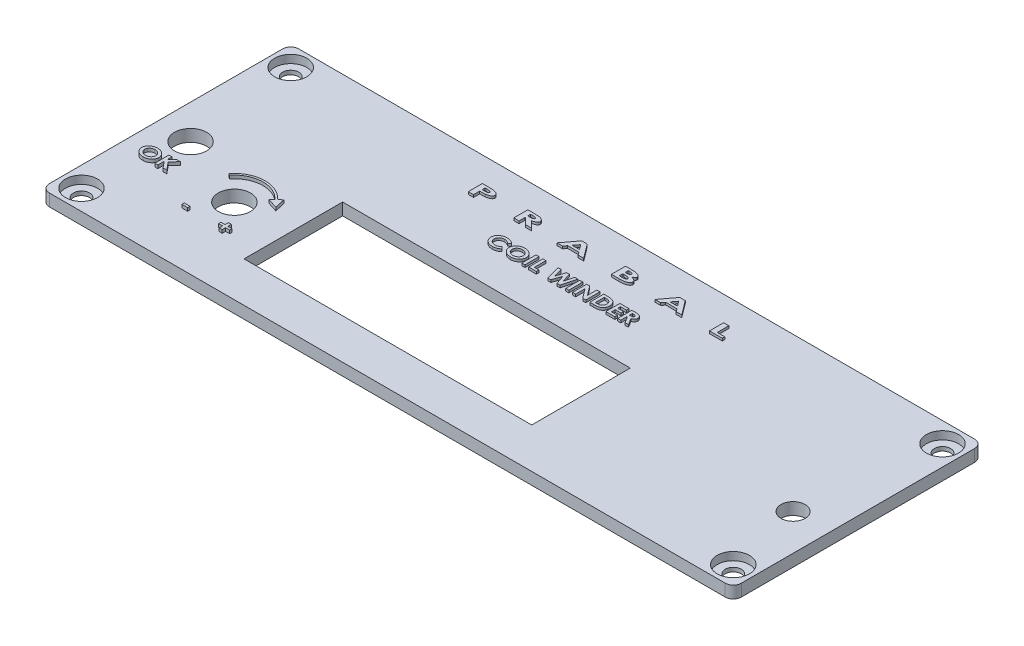
from build123d import *

# Parameters (mm, degrees)
SKETCH1_R           = 2
BOSS_EXTRUDE1_DEPTH = 3
SKETCH2_R           = 4
CUT_EXTRUDE1_DEPTH  = 2
SKETCH3_R           = 4
SKETCH3_R_2         = 3
SKETCH3_W           = 71.5
SKETCH3_H           = 24.5
CUT_EXTRUDE2_DEPTH  = 12
SKETCH4_W           = 1.435897436
SKETCH4_H           = 0.583333333
BOSS_EXTRUDE2_DEPTH = 0.8
SKETCH6_W           = 0.762820513
SKETCH6_H           = 3.5
BOSS_EXTRUDE3_DEPTH = 0.6


with BuildPart() as part:
    # Sketch1 → Boss-Extrude1 (new body)
    with BuildSketch(Plane(origin=(0, 0, 0), x_dir=(1, 0, 0), z_dir=(0, 1, 0))):
        with BuildLine():
            Line((86, -29), (86, 29))
            ThreePointArc((86, 29), (85.414213562, 30.414213562), (84, 31))
            Line((84, 31), (-84, 31))
            ThreePointArc((-84, 31), (-85.414213562, 30.414213562), (-86, 29))
            Line((-86, 29), (-86, -29))
            ThreePointArc((-86, -29), (-85.414213562, -30.414213562), (-84, -31))
            Line((-84, -31), (84, -31))
            ThreePointArc((84, -31), (85.414213562, -30.414213562), (86, -29))
        make_face()
        with Locations(Location((81, 26, 0), (0, 0, 270))):  # turned: the seam where the file's is
            Circle(SKETCH1_R, mode=Mode.SUBTRACT)
        with Locations(Location((81, -26, 0), (0, 0, 270))):  # turned: the seam where the file's is
            Circle(SKETCH1_R, mode=Mode.SUBTRACT)
        with Locations(Location((-81, -26, 0), (0, 0, 270))):  # turned: the seam where the file's is
            Circle(SKETCH1_R, mode=Mode.SUBTRACT)
        with Locations(Location((-81, 26, 0), (0, 0, 270))):  # turned: the seam where the file's is
            Circle(SKETCH1_R, mode=Mode.SUBTRACT)
    extrude(amount=BOSS_EXTRUDE1_DEPTH)

    # Sketch2 → Cut-Extrude1 (cut)
    with BuildSketch(Plane(origin=(0, 3, 0), x_dir=(1, 0, 0), z_dir=(0, 1, 0))):
        with Locations(Location((-81, 26, 0), (0, 0, 270))):  # turned: the seam where the file's is
            Circle(SKETCH2_R)
        with Locations(Location((81, 26, 0), (0, 0, 270))):  # turned: the seam where the file's is
            Circle(SKETCH2_R)
        with Locations(Location((-81, -26, 0), (0, 0, 270))):  # turned: the seam where the file's is
            Circle(SKETCH2_R)
        with Locations(Location((81, -26, 0), (0, 0, 270))):  # turned: the seam where the file's is
            Circle(SKETCH2_R)
    extrude(amount=-CUT_EXTRUDE1_DEPTH, mode=Mode.SUBTRACT)

    # Sketch3 → Cut-Extrude2 (cut)
    with BuildSketch(Plane(origin=(0, 3, 0), x_dir=(1, 0, 0), z_dir=(0, 1, 0))):
        with Locations(Location((-77.5, -2.4, 0), (0, 0, 270))):  # turned: the seam where the file's is
            Circle(SKETCH3_R)
        with Locations(Location((-59, -10, 0), (0, 0, 270))):  # turned: the seam where the file's is
            Circle(SKETCH3_R)
        with Locations(Location((76.991675758, -7.128858866, 0), (0, 0, 270))):  # turned: the seam where the file's is
            Circle(SKETCH3_R_2)
        with Locations((-9.85, -8.75)):
            Rectangle(SKETCH3_W, SKETCH3_H)
    extrude(amount=-CUT_EXTRUDE2_DEPTH, mode=Mode.SUBTRACT)

    # Sketch4 → Boss-Extrude2 (add)
    with BuildSketch(Plane(origin=(0, 3, 0), x_dir=(1, 0, 0), z_dir=(0, 1, 0))):
        with BuildLine():
            Line((-51.988382375, -6.724877483), (-52.556552367, -4.128219119))
            Line((-52.556552367, -4.128219119), (-53.359319029, -4.859763814))
            ThreePointArc((-53.359319029, -4.859763814), (-59.291497182, -2.374100757), (-65.016615493, -5.305359665))
            Line((-65.016615493, -5.305359665), (-64.622417733, -5.612944005))
            ThreePointArc((-64.622417733, -5.612944005), (-59.272398814, -2.873735877), (-53.728886239, -5.196542788))
            Line((-53.728886239, -5.196542788), (-54.52123948, -5.918597948))
            Line((-54.52123948, -5.918597948), (-51.988382375, -6.724877483))
        make_face()
        with BuildLine():
            add(Edge.make_bspline(
                [(-79.353333582, -8.706413119), (-79.281274588, -8.707971377), (-79.139274606, -8.711042093), (-78.930061876, -8.737121757), (-78.728448964, -8.778747518), (-78.534599499, -8.837959657), (-78.348694874, -8.913942148), (-78.170569568, -9.006930794), (-78.000279378, -9.116866731), (-77.866189353, -9.221479716), (-77.764512107, -9.311988503), (-77.69248916, -9.381731382), (-77.625225914, -9.453535126), (-77.564168185, -9.527840465), (-77.506507602, -9.603064925), (-77.455006675, -9.680874795), (-77.407917672, -9.76016674), (-77.365359297, -9.841197599), (-77.328721035, -9.92432177), (-77.295847214, -10.009080225), (-77.268903659, -10.095838462), (-77.245957229, -10.184407073), (-77.229783297, -10.274976568), (-77.21654424, -10.367040711), (-77.209887655, -10.461223578), (-77.208567499, -10.524647692), (-77.20790089, -10.556673535)],
                knots=[0, 0, 0, 0, 1.648128368, 3.247813819, 4.815582138, 6.353077473, 7.87824102, 9.404088637, 10.943618834, 12.509489415, 13.289676537, 14.057284384, 14.80259305, 15.539239416, 16.256815247, 16.970135158, 17.672570217, 18.366137315, 19.062686628, 19.74985535, 20.444904871, 21.140016092, 21.841616263, 22.548655906, 23.267147546, 24, 24, 24, 24], degree=3))
            add(Edge.make_bspline(
                [(-77.20790089, -10.556673535), (-77.208166311, -10.588244217), (-77.208694049, -10.65101636), (-77.217170278, -10.744084598), (-77.228461875, -10.835742881), (-77.246473725, -10.92523373), (-77.267957099, -11.013111077), (-77.294609907, -11.09915263), (-77.327134701, -11.182926582), (-77.363400414, -11.265297967), (-77.405133477, -11.345441036), (-77.451241969, -11.423995946), (-77.502789182, -11.500577492), (-77.558756844, -11.575613207), (-77.619876061, -11.648619407), (-77.686136016, -11.71949082), (-77.756813208, -11.788967798), (-77.857358382, -11.878037202), (-77.990149062, -11.981441584), (-78.159389854, -12.089620643), (-78.337132613, -12.181221073), (-78.522891316, -12.256628153), (-78.717282644, -12.314919962), (-78.920025577, -12.356080533), (-79.131151553, -12.381083869), (-79.274739141, -12.384277154), (-79.347724608, -12.385900298)],
                knots=[0, 0, 0, 0, 0.725776301, 1.443064634, 2.147736794, 2.848709645, 3.540911308, 4.227708172, 4.918447597, 5.606610135, 6.29653354, 6.995256734, 7.700359215, 8.418432472, 9.147207738, 9.888792953, 10.648941586, 11.425594641, 12.976974662, 14.514175085, 16.038230067, 17.569291758, 19.118361041, 20.698449866, 22.321824455, 24, 24, 24, 24], degree=3))
            add(Edge.make_bspline(
                [(-79.347724608, -12.385900298), (-79.424000764, -12.384459059), (-79.573507006, -12.381634137), (-79.792599759, -12.354284369), (-80.002323966, -12.313617749), (-80.20158508, -12.252105916), (-80.391859271, -12.176392393), (-80.571519819, -12.081307765), (-80.741815747, -11.970536391), (-80.899855422, -11.843418403), (-81.04317275, -11.704928133), (-81.169984337, -11.558924691), (-81.276039391, -11.405284469), (-81.364345894, -11.245994389), (-81.431592095, -11.079592941), (-81.480542091, -10.907171034), (-81.509909045, -10.728051412), (-81.513683776, -10.606327614), (-81.515593198, -10.544754465)],
                knots=[0, 0, 0, 0, 1.157019011, 2.26783273, 3.345970481, 4.39501922, 5.427728631, 6.449416413, 7.47446608, 8.506395619, 9.522255368, 10.495542035, 11.436096042, 12.350383781, 13.254015284, 14.153355931, 15.06588776, 16, 16, 16, 16], degree=3))
            add(Edge.make_bspline(
                [(-81.515593198, -10.544754465), (-81.51492466, -10.503342903), (-81.513594967, -10.420977152), (-81.498628609, -10.298965283), (-81.47670678, -10.17930472), (-81.444524469, -10.062563164), (-81.405080017, -9.947772806), (-81.354458216, -9.836241685), (-81.296562181, -9.726467816), (-81.228877161, -9.620292431), (-81.154589064, -9.51742531), (-81.071839241, -9.420372195), (-80.98284536, -9.328579918), (-80.887260078, -9.241881457), (-80.784408607, -9.161528847), (-80.675889814, -9.085249176), (-80.559463856, -9.016046404), (-80.437490612, -8.952036214), (-80.31121725, -8.893553349), (-80.181098328, -8.844354951), (-80.04921584, -8.800758528), (-79.914497363, -8.767234742), (-79.777827625, -8.738904541), (-79.638350639, -8.720914659), (-79.496605826, -8.707987117), (-79.401273886, -8.706939794), (-79.353333582, -8.706413119)],
                knots=[0, 0, 0, 0, 0.945898682, 1.881350319, 2.80526485, 3.723868994, 4.646145679, 5.576184113, 6.51996939, 7.480160434, 8.451252179, 9.417558632, 10.392051965, 11.371436227, 12.36407087, 13.373066218, 14.400787555, 15.456751901, 16.52026678, 17.578619197, 18.63425932, 19.69259826, 20.749480695, 21.822076479, 22.904770899, 24, 24, 24, 24], degree=3))
        make_face()
        with BuildLine():
            add(Edge.make_bspline(
                [(-79.364551531, -9.334618247), (-79.41250994, -9.335701272), (-79.506832958, -9.33783133), (-79.645391477, -9.354469021), (-79.778334015, -9.380580006), (-79.905189159, -9.418840851), (-80.026270674, -9.467364637), (-80.141875935, -9.526177891), (-80.250872301, -9.597018114), (-80.353410472, -9.676995872), (-80.446849189, -9.765308633), (-80.529062982, -9.86039568), (-80.597929953, -9.961728889), (-80.654582707, -10.068691282), (-80.699420437, -10.181364609), (-80.72947208, -10.300469451), (-80.749436738, -10.424893419), (-80.751646187, -10.509851612), (-80.752772685, -10.553167926)],
                knots=[0, 0, 0, 0, 1.115572756, 2.194071725, 3.242359846, 4.264238554, 5.271971266, 6.273921791, 7.276948881, 8.291830226, 9.295741301, 10.263602405, 11.21075812, 12.139965089, 13.075008802, 14.024611973, 14.992839609, 16, 16, 16, 16], degree=3))
            add(Edge.make_bspline(
                [(-80.752772685, -10.553167926), (-80.7514151, -10.601184814), (-80.748748553, -10.69549878), (-80.724110747, -10.8327498), (-80.685094049, -10.962574198), (-80.628772796, -11.084143892), (-80.557798422, -11.198455529), (-80.470306051, -11.304401317), (-80.367397012, -11.402899623), (-80.288902041, -11.459467921), (-80.248666115, -11.488464401)],
                knots=[0, 0, 0, 0, 1.037914569, 2.038654397, 3.006201782, 3.963123752, 4.928290618, 5.909010015, 6.928174417, 8, 8, 8, 8], degree=3))
            add(Edge.make_bspline(
                [(-80.248666115, -11.488464401), (-80.215807341, -11.510038688), (-80.1504234, -11.552968226), (-80.046641333, -11.607660127), (-79.939426142, -11.653819122), (-79.828638803, -11.692064897), (-79.714188007, -11.721417336), (-79.596070329, -11.742348932), (-79.474451988, -11.755349209), (-79.39216143, -11.756907036), (-79.350529095, -11.75769517)],
                knots=[0, 0, 0, 0, 0.990243603, 1.970433532, 2.951896849, 3.929818883, 4.921270474, 5.926466457, 6.950960545, 8, 8, 8, 8], degree=3))
            add(Edge.make_bspline(
                [(-79.350529095, -11.75769517), (-79.303509904, -11.756587552), (-79.211059443, -11.754409723), (-79.075171223, -11.738127785), (-78.944814148, -11.710594147), (-78.819383876, -11.672775522), (-78.699219421, -11.623842083), (-78.585022639, -11.562801385), (-78.475972895, -11.491674671), (-78.372891864, -11.411099854), (-78.278717308, -11.322122528), (-78.196419718, -11.226764745), (-78.126868742, -11.126134173), (-78.069772169, -11.020658765), (-78.025115492, -10.909667394), (-77.993861248, -10.793625996), (-77.974144898, -10.672563029), (-77.97187568, -10.590170466), (-77.970721403, -10.548260074)],
                knots=[0, 0, 0, 0, 1.104960777, 2.172605041, 3.211139271, 4.232890431, 5.247841741, 6.255318609, 7.271532584, 8.304444334, 9.326328372, 10.311776676, 11.259500763, 12.195902837, 13.125140341, 14.064582455, 15.015516643, 16, 16, 16, 16], degree=3))
            add(Edge.make_bspline(
                [(-77.970721403, -10.548260074), (-77.971887433, -10.506583562), (-77.974186068, -10.424425204), (-77.993814652, -10.3038254), (-78.025046769, -10.187877149), (-78.070696003, -10.077466449), (-78.127521888, -9.971213281), (-78.198492129, -9.870991345), (-78.280939097, -9.774766122), (-78.375944263, -9.685490397), (-78.479248438, -9.603410863), (-78.589516461, -9.531290416), (-78.705075362, -9.47008386), (-78.826711594, -9.420941224), (-78.953420844, -9.382336051), (-79.085400112, -9.354088756), (-79.223221193, -9.337910966), (-79.316833317, -9.335729988), (-79.364551531, -9.334618247)],
                knots=[0, 0, 0, 0, 0.972463577, 1.917051277, 2.844960661, 3.770042321, 4.700194893, 5.652301177, 6.631172647, 7.653950355, 8.691007868, 9.707991168, 10.725764563, 11.738993846, 12.765954592, 13.814701931, 14.886057511, 16, 16, 16, 16], degree=3))
        make_face(mode=Mode.SUBTRACT)
        Polygon((-76.489952172, -8.796156708), (-75.727131659, -8.796156708), (-75.727131659, -9.976144689), (-74.620761467, -8.796156708), (-73.647604416, -8.796156708), (-75.099627653, -10.344233631), (-73.505977813, -12.296156708), (-74.432159704, -12.296156708), (-75.727131659, -10.709518086), (-75.727131659, -12.296156708), (-76.489952172, -12.296156708), align=None)
        with Locations((-63.561499792, -17.482645039)):
            Rectangle(SKETCH4_W, SKETCH4_H)
        Polygon((-54.542269023, -16.787132219), (-54.542269023, -15.934568116), (-53.824320305, -15.934568116), (-53.824320305, -16.787132219), (-52.792269023, -16.787132219), (-52.792269023, -17.370465552), (-53.824320305, -17.370465552), (-53.824320305, -18.223029655), (-54.542269023, -18.223029655), (-54.542269023, -17.370465552), (-55.574320305, -17.370465552), (-55.574320305, -16.787132219), align=None)
    extrude(amount=BOSS_EXTRUDE2_DEPTH)

    # Sketch6 → Boss-Extrude3 (add)
    with BuildSketch(Plane(origin=(0, 3, 0), x_dir=(1, 0, 0), z_dir=(0, 1, 0))):
        with BuildLine():
            Line((-31.612179487, 24.246807214), (-30.209234776, 24.246807214))
            add(Edge.make_bspline(
                [(-30.209234776, 24.246807214), (-30.117619547, 24.246605844), (-29.94115208, 24.24621797), (-29.68637362, 24.24138205), (-29.451483293, 24.232864988), (-29.236388278, 24.222184907), (-29.041213589, 24.207348771), (-28.865793152, 24.190294702), (-28.71018815, 24.169727285), (-28.572198107, 24.144864911), (-28.447679731, 24.116146083), (-28.331318095, 24.085149719), (-28.222435202, 24.048171684), (-28.119173703, 24.009482823), (-28.023422237, 23.96509513), (-27.933786612, 23.91744081), (-27.85091549, 23.865659953), (-27.775092707, 23.809726793), (-27.707349609, 23.750142077), (-27.646808003, 23.688742547), (-27.596811176, 23.623011224), (-27.555936016, 23.554466949), (-27.522946475, 23.483514095), (-27.500882367, 23.408816818), (-27.48597482, 23.331738639), (-27.484643853, 23.279096305), (-27.483974359, 23.252616509)],
                knots=[0, 0, 0, 0, 2.083817351, 4.013808376, 5.795740628, 7.429903441, 8.911903755, 10.247479816, 11.438312011, 12.480993349, 13.435248238, 14.344388446, 15.218508883, 16.049746376, 16.851321187, 17.617108864, 18.35751293, 19.071967951, 19.7575608, 20.407936528, 21.029906838, 21.630685344, 22.220642402, 22.804145858, 23.398469404, 24, 24, 24, 24], degree=3))
            add(Edge.make_bspline(
                [(-27.483974359, 23.252616509), (-27.485287659, 23.223323683), (-27.48788547, 23.165380127), (-27.505592307, 23.080348389), (-27.536365607, 22.999499736), (-27.578991897, 22.922439157), (-27.633430248, 22.849101365), (-27.70030931, 22.780175343), (-27.778489369, 22.714762061), (-27.868806147, 22.65428925), (-27.96847225, 22.597323735), (-28.077066184, 22.544413593), (-28.194614269, 22.496999426), (-28.320630397, 22.453852574), (-28.455126563, 22.414460624), (-28.598048398, 22.379571452), (-28.74961822, 22.349272374), (-28.853891405, 22.3337016), (-28.907251603, 22.325733496)],
                knots=[0, 0, 0, 0, 0.763613765, 1.510489229, 2.252877417, 3.011001787, 3.799468799, 4.626880027, 5.509228559, 6.452248571, 7.456655607, 8.500362154, 9.59903774, 10.759040475, 11.971819688, 13.251610583, 14.593554007, 16, 16, 16, 16], degree=3))
            add(Edge.make_bspline(
                [(-28.907251603, 22.325733496), (-28.942513126, 22.321257224), (-29.019657426, 22.311464145), (-29.145786829, 22.301831326), (-29.291629758, 22.292717157), (-29.457110045, 22.284989466), (-29.642473081, 22.279726532), (-29.847675405, 22.275599391), (-30.072741108, 22.272609269), (-30.229332536, 22.27250339), (-30.310897436, 22.27244824)],
                knots=[0, 0, 0, 0, 0.606891322, 1.327742009, 2.15946742, 3.102340642, 4.156419961, 5.325996684, 6.607172714, 8, 8, 8, 8], degree=3))
            Line((-30.310897436, 22.27244824), (-30.310897436, 20.746807214))
            Line((-30.310897436, 20.746807214), (-31.612179487, 20.746807214))
            Line((-31.612179487, 20.746807214), (-31.612179487, 24.246807214))
        make_face()
        with BuildLine():
            Line((-30.310897436, 22.900653368), (-29.890224359, 22.900653368))
            add(Edge.make_bspline(
                [(-29.890224359, 22.900653368), (-29.850493845, 22.900844079), (-29.77406869, 22.90121093), (-29.664215123, 22.90242433), (-29.563932321, 22.905080574), (-29.473267012, 22.90952241), (-29.391877062, 22.914011873), (-29.319909303, 22.920499997), (-29.257167394, 22.927116953), (-29.187674596, 22.938059107), (-29.111611462, 22.95542801), (-29.029740043, 22.981739576), (-28.958191151, 23.013829875), (-28.897276465, 23.051650617), (-28.847351886, 23.09431672), (-28.811950266, 23.14340925), (-28.789118297, 23.196749897), (-28.786547832, 23.234401285), (-28.78525641, 23.253317631)],
                knots=[0, 0, 0, 0, 1.51779874, 2.919619996, 4.196833871, 5.349800447, 6.387340921, 7.310436361, 8.110034936, 8.79697462, 9.996829299, 11.086639547, 12.077494818, 12.98412298, 13.818981392, 14.567290304, 15.280195709, 16, 16, 16, 16], degree=3))
            add(Edge.make_bspline(
                [(-28.78525641, 23.253317631), (-28.786160994, 23.269790336), (-28.787943917, 23.302257832), (-28.803413673, 23.349010233), (-28.828879454, 23.391644572), (-28.862871936, 23.43179186), (-28.908139706, 23.466426139), (-28.96237101, 23.498170707), (-29.026005623, 23.52686185), (-29.072767563, 23.541516669), (-29.097255609, 23.549191028)],
                knots=[0, 0, 0, 0, 0.852496486, 1.680259921, 2.522008766, 3.415794299, 4.390452735, 5.460761322, 6.67026485, 8, 8, 8, 8], degree=3))
            add(Edge.make_bspline(
                [(-29.097255609, 23.549191028), (-29.117986519, 23.554864036), (-29.163266264, 23.567254827), (-29.238376332, 23.58045223), (-29.325377969, 23.592305832), (-29.424553676, 23.601935333), (-29.535847418, 23.609413103), (-29.65926739, 23.615157352), (-29.794629963, 23.617463944), (-29.888821949, 23.618212205), (-29.937900641, 23.618602086)],
                knots=[0, 0, 0, 0, 0.609654169, 1.331585754, 2.161666601, 3.101399871, 4.158434339, 5.326900258, 6.607182602, 8, 8, 8, 8], degree=3))
            Line((-29.937900641, 23.618602086), (-30.310897436, 23.618602086))
            Line((-30.310897436, 23.618602086), (-30.310897436, 22.900653368))
        make_face(mode=Mode.SUBTRACT)
        with BuildLine():
            Line((-20.304487179, 24.246807214), (-18.916967147, 24.246807214))
            add(Edge.make_bspline(
                [(-18.916967147, 24.246807214), (-18.825350932, 24.246635076), (-18.649115231, 24.246303945), (-18.394825013, 24.241095539), (-18.161066929, 24.233835231), (-17.947859814, 24.22284922), (-17.755245167, 24.208124177), (-17.583145966, 24.190896819), (-17.431238178, 24.171160862), (-17.297684328, 24.147002674), (-17.17727879, 24.119024202), (-17.064942932, 24.08755038), (-16.958384893, 24.051967823), (-16.857901876, 24.012065855), (-16.763571621, 23.967752514), (-16.675009198, 23.919359804), (-16.592179067, 23.866881426), (-16.515758401, 23.81044445), (-16.447348162, 23.750130755), (-16.386047978, 23.688069362), (-16.33568526, 23.62168735), (-16.293612795, 23.553300442), (-16.261141927, 23.481938602), (-16.237755121, 23.408076766), (-16.224213784, 23.33116823), (-16.222184623, 23.279077613), (-16.221153846, 23.252616509)],
                knots=[0, 0, 0, 0, 2.103292011, 4.045955615, 5.838994559, 7.472355329, 8.946805897, 10.273510151, 11.442850519, 12.462642941, 13.388011713, 14.279794316, 15.140028421, 15.965997331, 16.760467608, 17.531248846, 18.281436869, 19.010074944, 19.709646774, 20.37368749, 21.008991884, 21.618155999, 22.213626598, 22.80416975, 23.39253958, 24, 24, 24, 24], degree=3))
            add(Edge.make_bspline(
                [(-16.221153846, 23.252616509), (-16.221935104, 23.224948092), (-16.223478516, 23.170287826), (-16.240675614, 23.090491631), (-16.266390508, 23.013907504), (-16.303668337, 22.941044727), (-16.35062853, 22.871247809), (-16.409292925, 22.806069587), (-16.476598846, 22.742867356), (-16.556145018, 22.685460822), (-16.644544242, 22.629261828), (-16.744748587, 22.579087013), (-16.854109899, 22.530124967), (-16.974845927, 22.486506604), (-17.105766301, 22.445090802), (-17.247400255, 22.407641595), (-17.399351592, 22.372951541), (-17.504590538, 22.353829637), (-17.558894231, 22.343962663)],
                knots=[0, 0, 0, 0, 0.756252596, 1.494012779, 2.224385, 2.962561159, 3.727344049, 4.520578125, 5.358087056, 6.249937379, 7.201385599, 8.222871841, 9.314176868, 10.48006394, 11.734562655, 13.072273122, 14.489281904, 16, 16, 16, 16], degree=3))
            Line((-17.558894231, 22.343962663), (-15.884615385, 20.746807214))
            Line((-15.884615385, 20.746807214), (-17.356270032, 20.746807214))
            Line((-17.356270032, 20.746807214), (-18.954827724, 22.27244824))
            Line((-18.954827724, 22.27244824), (-19.003205128, 22.27244824))
            Line((-19.003205128, 22.27244824), (-19.003205128, 20.746807214))
            Line((-19.003205128, 20.746807214), (-20.304487179, 20.746807214))
            Line((-20.304487179, 20.746807214), (-20.304487179, 24.246807214))
        make_face()
        with BuildLine():
            Line((-19.003205128, 22.900653368), (-18.600060096, 22.900653368))
            add(Edge.make_bspline(
                [(-18.600060096, 22.900653368), (-18.550747183, 22.900989831), (-18.456315037, 22.901634143), (-18.320462801, 22.904633816), (-18.196809582, 22.911821697), (-18.084844199, 22.920969503), (-17.984793034, 22.931309366), (-17.896927219, 22.946372866), (-17.820851844, 22.962554563), (-17.756078957, 22.982222264), (-17.700829452, 23.004901728), (-17.653375654, 23.030783961), (-17.612888236, 23.060344975), (-17.579382721, 23.093378419), (-17.5534149, 23.130382645), (-17.536238761, 23.171144623), (-17.523969797, 23.214747554), (-17.522957874, 23.245280343), (-17.522435897, 23.26102997)],
                knots=[0, 0, 0, 0, 1.907101129, 3.652018071, 5.254293012, 6.696128307, 7.996625372, 9.142205946, 10.142119529, 11.002629017, 11.756258489, 12.448004148, 13.087916674, 13.688653997, 14.260266547, 14.822804161, 15.392770955, 16, 16, 16, 16], degree=3))
            add(Edge.make_bspline(
                [(-17.522435897, 23.26102997), (-17.523711735, 23.279718985), (-17.526273033, 23.317237954), (-17.549849637, 23.370518181), (-17.586968221, 23.419393922), (-17.638123833, 23.462682439), (-17.700218148, 23.501947091), (-17.77269579, 23.535231072), (-17.854970642, 23.562584723), (-17.931162916, 23.579855059), (-18.000933458, 23.590588057), (-18.064039015, 23.598375164), (-18.137272711, 23.604286667), (-18.220460295, 23.610057305), (-18.313739924, 23.61406895), (-18.417051227, 23.616867657), (-18.530412877, 23.618036271), (-18.609408325, 23.618408347), (-18.650540865, 23.618602086)],
                knots=[0, 0, 0, 0, 0.698236454, 1.401738552, 2.147058196, 2.985948884, 3.9005634, 4.896971427, 5.970061203, 7.1484661, 7.823125376, 8.61815986, 9.53348864, 10.579291391, 11.746683529, 13.036125197, 14.456725003, 16, 16, 16, 16], degree=3))
            Line((-18.650540865, 23.618602086), (-19.003205128, 23.618602086))
            Line((-19.003205128, 23.618602086), (-19.003205128, 22.900653368))
        make_face(mode=Mode.SUBTRACT)
        Polygon((-6.923577724, 24.246807214), (-5.55078125, 24.246807214), (-2.916666667, 20.746807214), (-4.309795673, 20.746807214), (-4.846153846, 21.464755932), (-7.62890625, 21.464755932), (-8.165264423, 20.746807214), (-9.557692308, 20.746807214), align=None)
        Polygon((-6.237179487, 23.308005131), (-7.159855769, 22.09296106), (-5.315204327, 22.09296106), align=None, mode=Mode.SUBTRACT)
        with BuildLine():
            Line((3.971153846, 20.746807214), (3.971153846, 24.246807214))
            Line((3.971153846, 24.246807214), (5.055088141, 24.246807214))
            add(Edge.make_bspline(
                [(5.055088141, 24.246807214), (5.131044921, 24.246816832), (5.277592417, 24.246835389), (5.489568737, 24.242931216), (5.685651934, 24.238053829), (5.866137788, 24.232357889), (6.030652166, 24.2228823), (6.179351045, 24.212725449), (6.312200931, 24.200518811), (6.395193823, 24.189558132), (6.434194712, 24.184407374)],
                knots=[0, 0, 0, 0, 1.319570342, 2.545917945, 3.683128378, 4.727238704, 5.682843878, 6.545757585, 7.316607172, 8, 8, 8, 8], degree=3))
            add(Edge.make_bspline(
                [(6.434194712, 24.184407374), (6.484515037, 24.177138905), (6.582927148, 24.162923867), (6.725782488, 24.134654528), (6.860963764, 24.102342697), (6.988462999, 24.066343853), (7.107954441, 24.025129616), (7.21915178, 23.978440165), (7.322914143, 23.92841382), (7.41813046, 23.873967449), (7.503768681, 23.816206933), (7.578387168, 23.755147721), (7.642304698, 23.691903106), (7.694855887, 23.625825383), (7.735461932, 23.556676692), (7.763561198, 23.484666579), (7.782335955, 23.410390774), (7.784278876, 23.359533994), (7.78525641, 23.333946637)],
                knots=[0, 0, 0, 0, 1.417346654, 2.771923144, 4.058400563, 5.291768156, 6.464304676, 7.580045267, 8.652477159, 9.674056707, 10.635536998, 11.529085064, 12.358436799, 13.13796425, 13.876690453, 14.584539506, 15.287845329, 16, 16, 16, 16], degree=3))
            add(Edge.make_bspline(
                [(7.78525641, 23.333946637), (7.784670853, 23.317324543), (7.783509959, 23.284370496), (7.775586771, 23.235424152), (7.76232618, 23.187625641), (7.743092463, 23.141246122), (7.71900177, 23.095882413), (7.689543843, 23.051609176), (7.653946896, 23.008991473), (7.61404559, 22.966391803), (7.567211238, 22.925777414), (7.514227572, 22.885941637), (7.455503644, 22.845590515), (7.388918037, 22.807480033), (7.316482981, 22.76875129), (7.236570181, 22.7319046), (7.150680503, 22.694601223), (7.090534266, 22.67140136), (7.059595353, 22.65946747)],
                knots=[0, 0, 0, 0, 0.756783706, 1.500357685, 2.251734652, 3.010610576, 3.781847217, 4.587626815, 5.427000592, 6.307722661, 7.242770749, 8.245272196, 9.32558443, 10.484591136, 11.73660469, 13.064858731, 14.490178491, 16, 16, 16, 16], degree=3))
            add(Edge.make_bspline(
                [(7.059595353, 22.65946747), (7.110631822, 22.646950978), (7.209593086, 22.622681118), (7.351973156, 22.581876808), (7.484088625, 22.539467467), (7.605299656, 22.494077272), (7.715880633, 22.44614346), (7.816376623, 22.397048391), (7.905732478, 22.344255958), (7.984792953, 22.289500624), (8.054193604, 22.232488105), (8.114299722, 22.172779882), (8.164908846, 22.110159047), (8.207190167, 22.04544885), (8.238493938, 21.977395888), (8.262408199, 21.907565252), (8.27571131, 21.83451428), (8.277793051, 21.784984252), (8.278846154, 21.759928208)],
                knots=[0, 0, 0, 0, 1.546158762, 2.998048831, 4.357274965, 5.628196061, 6.804803035, 7.902753431, 8.917055622, 9.855656414, 10.730007103, 11.556676242, 12.34393285, 13.095539958, 13.824662081, 14.542310515, 15.262590117, 16, 16, 16, 16], degree=3))
            add(Edge.make_bspline(
                [(8.278846154, 21.759928208), (8.277865908, 21.735784994), (8.27590804, 21.687563215), (8.261140422, 21.616223198), (8.238267412, 21.546231762), (8.204208734, 21.478492655), (8.162597379, 21.41154795), (8.109378619, 21.347713842), (8.048600922, 21.284474702), (7.978388519, 21.223855099), (7.9008696, 21.166430301), (7.818115919, 21.111305638), (7.729295849, 21.061046986), (7.635393611, 21.013838613), (7.535635071, 20.9714483), (7.430876045, 20.932045173), (7.320763128, 20.896197617), (7.203963959, 20.86461046), (7.079164332, 20.836149143), (6.943770098, 20.812997335), (6.797555968, 20.791333058), (6.639528375, 20.776281364), (6.470593545, 20.762387566), (6.29030051, 20.753846387), (6.098862957, 20.748054921), (5.967486132, 20.747230885), (5.899939904, 20.746807214)],
                knots=[0, 0, 0, 0, 0.618713376, 1.235770065, 1.861181169, 2.501770574, 3.175161626, 3.878093952, 4.628285709, 5.422659979, 6.253304739, 7.101026803, 7.970749554, 8.868615401, 9.794835647, 10.748793623, 11.738109321, 12.763087413, 13.850616593, 15.019194587, 16.284590858, 17.640065655, 19.08888482, 20.631081193, 22.267900294, 24, 24, 24, 24], degree=3))
            Line((5.899939904, 20.746807214), (3.971153846, 20.746807214))
        make_face()
        with BuildLine():
            Line((5.272435897, 23.618602086), (5.272435897, 22.855781573))
            Line((5.272435897, 22.855781573), (5.554286859, 22.855781573))
            add(Edge.make_bspline(
                [(5.554286859, 22.855781573), (5.592387113, 22.855976603), (5.666051417, 22.856353679), (5.772693256, 22.861326231), (5.871667726, 22.869450581), (5.963072831, 22.88158903), (6.047000047, 22.895734495), (6.12336001, 22.914026576), (6.192018559, 22.935579135), (6.253467803, 22.960140113), (6.307678274, 22.98719024), (6.354585371, 23.017445534), (6.393802089, 23.05051994), (6.427019956, 23.085050019), (6.452633165, 23.122718869), (6.471146635, 23.162927967), (6.481992317, 23.20577776), (6.483308935, 23.235028551), (6.483974359, 23.249812022)],
                knots=[0, 0, 0, 0, 1.656597457, 3.202920872, 4.641000582, 5.97336186, 7.211383623, 8.340280512, 9.384835837, 10.337829312, 11.214981261, 12.015492787, 12.758461544, 13.441463176, 14.092571545, 14.729244683, 15.357755008, 16, 16, 16, 16], degree=3))
            add(Edge.make_bspline(
                [(6.483974359, 23.249812022), (6.483229841, 23.263641193), (6.481759516, 23.290952002), (6.47215464, 23.331031714), (6.453400289, 23.367647622), (6.430734307, 23.403667346), (6.398620104, 23.435501082), (6.361651167, 23.466861388), (6.316688962, 23.494596648), (6.265438737, 23.520653249), (6.207094724, 23.543432988), (6.14200199, 23.563884536), (6.069872305, 23.581258013), (5.990479929, 23.595139934), (5.904081409, 23.605350668), (5.810769661, 23.612922606), (5.710460441, 23.618062339), (5.641232764, 23.618418228), (5.60546875, 23.618602086)],
                knots=[0, 0, 0, 0, 0.638559861, 1.261072475, 1.883304783, 2.529378969, 3.215862904, 3.958734525, 4.763527671, 5.646136426, 6.60939454, 7.649683162, 8.792726955, 10.030303468, 11.366611036, 12.805832474, 14.34984708, 16, 16, 16, 16], degree=3))
            Line((5.60546875, 23.618602086), (5.272435897, 23.618602086))
        make_face(mode=Mode.SUBTRACT)
        with BuildLine():
            Line((5.272435897, 22.27244824), (5.272435897, 21.375012342))
            Line((5.272435897, 21.375012342), (5.599158654, 21.375012342))
            add(Edge.make_bspline(
                [(5.599158654, 21.375012342), (5.664132109, 21.375211474), (5.788724427, 21.375593327), (5.967332021, 21.380384541), (6.129322788, 21.388826661), (6.274574635, 21.399581001), (6.403264454, 21.414018322), (6.515350706, 21.432041472), (6.611319973, 21.452517041), (6.692000951, 21.476755128), (6.759210117, 21.50592027), (6.817436195, 21.535691457), (6.867109453, 21.568907342), (6.906644885, 21.60670133), (6.938635515, 21.646404863), (6.961327146, 21.689658474), (6.975400009, 21.736157982), (6.97683735, 21.768244037), (6.977564103, 21.78446747)],
                knots=[0, 0, 0, 0, 2.012988271, 3.860082116, 5.534957092, 7.038268782, 8.372027096, 9.545747991, 10.554167636, 11.410724392, 12.150418645, 12.820845839, 13.435416837, 13.993708496, 14.509382017, 15.008155457, 15.498501003, 16, 16, 16, 16], degree=3))
            add(Edge.make_bspline(
                [(6.977564103, 21.78446747), (6.976787735, 21.803066127), (6.975252793, 21.839837203), (6.957772936, 21.892779583), (6.93142522, 21.942492462), (6.895096915, 21.989677502), (6.847050235, 22.032068597), (6.789696302, 22.07232021), (6.721790742, 22.109198412), (6.643353948, 22.143727517), (6.552669958, 22.174698561), (6.448718759, 22.20077005), (6.331186803, 22.223099997), (6.200065732, 22.240670619), (6.055381088, 22.255791082), (5.896754795, 22.264736495), (5.724483242, 22.271439326), (5.605009092, 22.272103767), (5.54306891, 22.27244824)],
                knots=[0, 0, 0, 0, 0.544216312, 1.075960483, 1.619267566, 2.191611696, 2.813364583, 3.493007407, 4.245476687, 5.078063713, 6.006835397, 7.05534177, 8.22213207, 9.517656304, 10.938539662, 12.492308336, 14.181472246, 16, 16, 16, 16], degree=3))
            Line((5.54306891, 22.27244824), (5.272435897, 22.27244824))
        make_face(mode=Mode.SUBTRACT)
        Polygon((17.441806891, 24.246807214), (18.814603365, 24.246807214), (21.448717949, 20.746807214), (20.055588942, 20.746807214), (19.519230769, 21.464755932), (16.736478365, 21.464755932), (16.200120192, 20.746807214), (14.807692308, 20.746807214), align=None)
        Polygon((18.128205128, 23.308005131), (17.205528846, 22.09296106), (19.050180288, 22.09296106), align=None, mode=Mode.SUBTRACT)
        Polygon((28.336538462, 24.246807214), (29.637820513, 24.246807214), (29.637820513, 21.375012342), (31.522435897, 21.375012342), (31.522435897, 20.746807214), (28.336538462, 20.746807214), align=None)
        with BuildLine():
            Line((-15.054487179, 14.926118757), (-15.599258814, 14.48581427))
            add(Edge.make_bspline(
                [(-15.599258814, 14.48581427), (-15.645567928, 14.526360038), (-15.736784029, 14.606223947), (-15.882958666, 14.710161472), (-16.033932406, 14.797034748), (-16.187992385, 14.870813288), (-16.347761993, 14.925590377), (-16.511201215, 14.965997782), (-16.67916848, 14.990649294), (-16.792719756, 14.993426353), (-16.850060096, 14.994828693)],
                knots=[0, 0, 0, 0, 1.067527142, 2.102732167, 3.10569656, 4.087098218, 5.061774412, 6.030552988, 7.005482224, 8, 8, 8, 8], degree=3))
            add(Edge.make_bspline(
                [(-16.850060096, 14.994828693), (-16.89801353, 14.993722178), (-16.992326763, 14.991545921), (-17.131002544, 14.975237329), (-17.263731882, 14.947893101), (-17.390856183, 14.910110103), (-17.511809753, 14.860638763), (-17.627507213, 14.8009501), (-17.737035784, 14.729857627), (-17.839429824, 14.648923304), (-17.933077123, 14.560458884), (-18.015645418, 14.465973294), (-18.084644754, 14.36544277), (-18.142245944, 14.260802326), (-18.185773528, 14.150139541), (-18.217397311, 14.034781525), (-18.236892348, 13.914124491), (-18.239209296, 13.831973981), (-18.240384615, 13.79030145)],
                knots=[0, 0, 0, 0, 1.123147555, 2.20896959, 3.265468395, 4.294285714, 5.31091199, 6.322173291, 7.339580517, 8.36473528, 9.375462965, 10.353472599, 11.298027794, 12.226485346, 13.145501207, 14.076521539, 15.024276102, 16, 16, 16, 16], degree=3))
            add(Edge.make_bspline(
                [(-18.240384615, 13.79030145), (-18.239866655, 13.761066331), (-18.238845108, 13.703407338), (-18.230102922, 13.618147391), (-18.216330826, 13.535392461), (-18.196386496, 13.455401222), (-18.172174412, 13.37753698), (-18.140735004, 13.302709728), (-18.105434534, 13.229326701), (-18.063146084, 13.159526677), (-18.016064429, 13.09294216), (-17.964830666, 13.029418115), (-17.908497314, 12.970003052), (-17.848277108, 12.913501431), (-17.78259682, 12.861605651), (-17.712460745, 12.813296639), (-17.637934189, 12.768500529), (-17.559635123, 12.726736308), (-17.477141319, 12.691227958), (-17.392872801, 12.65816551), (-17.305563003, 12.63173154), (-17.216019565, 12.610430678), (-17.124468964, 12.592163198), (-17.030448864, 12.581049065), (-16.934350764, 12.572519042), (-16.869478052, 12.572009115), (-16.836738782, 12.57175177)],
                knots=[0, 0, 0, 0, 1.01124304, 1.994425115, 2.962157876, 3.911336384, 4.844712957, 5.780188581, 6.716781774, 7.659740626, 8.599713336, 9.536725274, 10.480550418, 11.430279814, 12.391266821, 13.373650588, 14.374854857, 15.398436071, 16.441097469, 17.480241446, 18.528905263, 19.593809216, 20.664224499, 21.756407018, 22.867727367, 24, 24, 24, 24], degree=3))
            add(Edge.make_bspline(
                [(-16.836738782, 12.57175177), (-16.781288517, 12.573105348), (-16.672575473, 12.575759106), (-16.513136858, 12.596418836), (-16.361280447, 12.630750257), (-16.239561786, 12.67077996), (-16.144359031, 12.711070333), (-16.071801928, 12.748020643), (-15.996642658, 12.78909712), (-15.920259313, 12.836324986), (-15.842073324, 12.889101037), (-15.762684335, 12.948046302), (-15.680946234, 13.011936337), (-15.626926567, 13.057453332), (-15.599258814, 13.080766193)],
                knots=[0, 0, 0, 0, 1.454897132, 2.85239928, 4.210863431, 5.535567464, 6.208840487, 6.921998941, 7.671422934, 8.456156138, 9.277796038, 10.146309466, 11.050578152, 12, 12, 12, 12], degree=3))
            Line((-15.599258814, 13.080766193), (-15.071314103, 12.611715713))
            add(Edge.make_bspline(
                [(-15.071314103, 12.611715713), (-15.108505278, 12.581313502), (-15.181489609, 12.521651904), (-15.292085909, 12.438353777), (-15.401289352, 12.362455738), (-15.508192368, 12.292761542), (-15.614116218, 12.230831539), (-15.719037274, 12.176991218), (-15.821630096, 12.128927028), (-15.924079498, 12.088596361), (-16.027255047, 12.053858176), (-16.133395509, 12.024671792), (-16.242564897, 11.999264205), (-16.355627664, 11.979045869), (-16.472083483, 11.962842424), (-16.592355817, 11.951980428), (-16.715817159, 11.944510939), (-16.799334091, 11.943870905), (-16.841646635, 11.943546642)],
                knots=[0, 0, 0, 0, 1.189352786, 2.333997676, 3.427225781, 4.481802152, 5.493180527, 6.463754106, 7.401030282, 8.297247864, 9.188444371, 10.095433293, 11.021910727, 11.962895372, 12.938424752, 13.932301483, 14.952432975, 16, 16, 16, 16], degree=3))
            add(Edge.make_bspline(
                [(-16.841646635, 11.943546642), (-16.919062751, 11.94522478), (-17.070764469, 11.948513197), (-17.293112871, 11.972457923), (-17.504677786, 12.012926312), (-17.705557399, 12.069808017), (-17.895600962, 12.142672817), (-18.074715655, 12.232219247), (-18.243109841, 12.337825791), (-18.373841896, 12.438986866), (-18.471751858, 12.526300002), (-18.540221642, 12.594771701), (-18.603566011, 12.665650847), (-18.663883086, 12.73754727), (-18.717778477, 12.813206839), (-18.767359438, 12.89067442), (-18.812763012, 12.970260596), (-18.852399837, 13.052495268), (-18.888429536, 13.136558246), (-18.919224827, 13.222984161), (-18.945393494, 13.311662028), (-18.966066923, 13.40284703), (-18.983163902, 13.496129248), (-18.99491805, 13.59163907), (-19.002195473, 13.689458167), (-19.002865671, 13.75546607), (-19.003205128, 13.788899206)],
                knots=[0, 0, 0, 0, 1.750181118, 3.429589313, 5.049357415, 6.614963186, 8.143845363, 9.644423126, 11.135443565, 12.630988945, 13.375670058, 14.100534031, 14.818897545, 15.524555374, 16.221133255, 16.91739039, 17.603609734, 18.29131262, 18.980293258, 19.670569505, 20.364476687, 21.069461537, 21.783595391, 22.50782351, 23.244209602, 24, 24, 24, 24], degree=3))
            add(Edge.make_bspline(
                [(-19.003205128, 13.788899206), (-19.002485724, 13.831939799), (-19.001059022, 13.917296744), (-18.987014776, 14.043031378), (-18.966305358, 14.16544491), (-18.936356105, 14.283971145), (-18.896253456, 14.398601884), (-18.850140464, 14.510337944), (-18.792975356, 14.617374065), (-18.728795894, 14.721234118), (-18.655932338, 14.820474961), (-18.575347036, 14.914912888), (-18.487926507, 15.004867857), (-18.392045881, 15.088842818), (-18.289428164, 15.168473727), (-18.179126145, 15.242575354), (-18.061693307, 15.312244412), (-17.937536781, 15.376204818), (-17.808442787, 15.434277121), (-17.675889045, 15.484706117), (-17.541054365, 15.527481672), (-17.404003302, 15.562993309), (-17.264053385, 15.589104424), (-17.121875986, 15.609181695), (-16.9769055, 15.620261926), (-16.879524227, 15.622104748), (-16.830428686, 15.623033821)],
                knots=[0, 0, 0, 0, 0.977774021, 1.939095111, 2.871639716, 3.797825489, 4.713212348, 5.629600177, 6.541884779, 7.467430742, 8.402256353, 9.336659416, 10.286883314, 11.250183051, 12.230737116, 13.236849212, 14.267954381, 15.332150946, 16.409074216, 17.483256768, 18.553229402, 19.622410832, 20.698430043, 21.786804513, 22.884199939, 24, 24, 24, 24], degree=3))
            add(Edge.make_bspline(
                [(-16.830428686, 15.623033821), (-16.788579747, 15.622507782), (-16.705264813, 15.621460516), (-16.580820851, 15.612616698), (-16.457425995, 15.599054131), (-16.33547194, 15.57812791), (-16.214306858, 15.553380764), (-16.094774824, 15.521292312), (-15.975844881, 15.485339306), (-15.859167198, 15.442134683), (-15.744480503, 15.395087657), (-15.633822765, 15.342161033), (-15.526618694, 15.285722542), (-15.424477591, 15.222721134), (-15.325291315, 15.156463212), (-15.230620807, 15.084685223), (-15.139768262, 15.008433225), (-15.082924658, 14.953567001), (-15.054487179, 14.926118757)],
                knots=[0, 0, 0, 0, 1.026787777, 2.044179787, 3.060002783, 4.071624424, 5.079386237, 6.093427, 7.107451547, 8.127055474, 9.145206858, 10.148209072, 11.135946312, 12.116532237, 13.091551623, 14.061888063, 15.030409504, 16, 16, 16, 16], degree=3))
        make_face()
        with BuildLine():
            add(Edge.make_bspline(
                [(-12.353766026, 15.623033821), (-12.281707031, 15.621475563), (-12.139707049, 15.618404847), (-11.930494319, 15.592325183), (-11.728881407, 15.550699422), (-11.535031942, 15.491487283), (-11.349127317, 15.415504792), (-11.171002011, 15.322516146), (-11.000711822, 15.212580209), (-10.866621797, 15.107967224), (-10.764944551, 15.017458437), (-10.692921603, 14.947715558), (-10.625658357, 14.875911814), (-10.564600628, 14.801606475), (-10.506940045, 14.726382015), (-10.455439119, 14.648572145), (-10.408350115, 14.5692802), (-10.365791741, 14.488249341), (-10.329153478, 14.40512517), (-10.296279657, 14.320366715), (-10.269336102, 14.233608478), (-10.246389672, 14.145039867), (-10.23021574, 14.054470373), (-10.216976683, 13.962406229), (-10.210320098, 13.868223362), (-10.208999942, 13.804799248), (-10.208333333, 13.772773405)],
                knots=[0, 0, 0, 0, 1.648128368, 3.247813819, 4.815582138, 6.353077473, 7.87824102, 9.404088637, 10.943618834, 12.509489415, 13.289676537, 14.057284384, 14.80259305, 15.539239416, 16.256815247, 16.970135158, 17.672570217, 18.366137315, 19.062686628, 19.74985535, 20.444904871, 21.140016092, 21.841616263, 22.548655906, 23.267147546, 24, 24, 24, 24], degree=3))
            add(Edge.make_bspline(
                [(-10.208333333, 13.772773405), (-10.208598754, 13.741202723), (-10.209126492, 13.67843058), (-10.217602721, 13.585362342), (-10.228894318, 13.493704059), (-10.246906168, 13.40421321), (-10.268389542, 13.316335863), (-10.29504235, 13.23029431), (-10.327567144, 13.146520358), (-10.363832857, 13.064148973), (-10.40556592, 12.984005904), (-10.451674412, 12.905450994), (-10.503221625, 12.828869448), (-10.559189287, 12.753833733), (-10.620308505, 12.680827533), (-10.686568459, 12.60995612), (-10.757245652, 12.540479142), (-10.857790826, 12.451409738), (-10.990581505, 12.348005356), (-11.159822297, 12.239826297), (-11.337565056, 12.148225867), (-11.523323759, 12.072818787), (-11.717715087, 12.014526978), (-11.92045802, 11.973366407), (-12.131583996, 11.948363071), (-12.275171584, 11.945169786), (-12.348157051, 11.943546642)],
                knots=[0, 0, 0, 0, 0.725776301, 1.443064634, 2.147736794, 2.848709645, 3.540911308, 4.227708172, 4.918447597, 5.606610135, 6.29653354, 6.995256734, 7.700359215, 8.418432472, 9.147207738, 9.888792953, 10.648941586, 11.425594641, 12.976974662, 14.514175085, 16.038230067, 17.569291758, 19.118361041, 20.698449866, 22.321824455, 24, 24, 24, 24], degree=3))
            add(Edge.make_bspline(
                [(-12.348157051, 11.943546642), (-12.424433207, 11.944987881), (-12.573939449, 11.947812803), (-12.793032202, 11.975162571), (-13.00275641, 12.015829191), (-13.202017523, 12.077341024), (-13.392291714, 12.153054547), (-13.571952262, 12.248139175), (-13.74224819, 12.358910549), (-13.900287865, 12.486028537), (-14.043605194, 12.624518807), (-14.17041678, 12.770522249), (-14.276471834, 12.924162471), (-14.364778337, 13.083452551), (-14.432024538, 13.249853999), (-14.480974534, 13.422275906), (-14.510341488, 13.601395528), (-14.514116219, 13.723119326), (-14.516025641, 13.784692475)],
                knots=[0, 0, 0, 0, 1.157019011, 2.26783273, 3.345970481, 4.39501922, 5.427728631, 6.449416413, 7.47446608, 8.506395619, 9.522255368, 10.495542035, 11.436096042, 12.350383781, 13.254015284, 14.153355931, 15.06588776, 16, 16, 16, 16], degree=3))
            add(Edge.make_bspline(
                [(-14.516025641, 13.784692475), (-14.515357103, 13.826104037), (-14.51402741, 13.908469788), (-14.499061052, 14.030481657), (-14.477139224, 14.15014222), (-14.444956912, 14.266883776), (-14.405512461, 14.381674134), (-14.354890659, 14.493205255), (-14.296994624, 14.602979124), (-14.229309604, 14.709154509), (-14.155021507, 14.81202163), (-14.072271684, 14.909074745), (-13.983277803, 15.000867022), (-13.887692522, 15.087565483), (-13.78484105, 15.167918093), (-13.676322258, 15.244197764), (-13.559896299, 15.313400536), (-13.437923056, 15.377410726), (-13.311649693, 15.435893591), (-13.181530771, 15.485091989), (-13.049648283, 15.528688412), (-12.914929806, 15.562212198), (-12.778260068, 15.590542399), (-12.638783082, 15.608532281), (-12.497038269, 15.621459823), (-12.401706329, 15.622507146), (-12.353766026, 15.623033821)],
                knots=[0, 0, 0, 0, 0.945898682, 1.881350319, 2.80526485, 3.723868994, 4.646145679, 5.576184113, 6.51996939, 7.480160434, 8.451252179, 9.417558632, 10.392051965, 11.371436227, 12.36407087, 13.373066218, 14.400787555, 15.456751901, 16.52026678, 17.578619197, 18.63425932, 19.69259826, 20.749480695, 21.822076479, 22.904770899, 24, 24, 24, 24], degree=3))
        make_face()
        with BuildLine():
            add(Edge.make_bspline(
                [(-12.364983974, 14.994828693), (-12.412942383, 14.993745668), (-12.507265401, 14.99161561), (-12.64582392, 14.974977919), (-12.778766458, 14.948866934), (-12.905621602, 14.910606089), (-13.026703117, 14.862082303), (-13.142308379, 14.803269049), (-13.251304745, 14.732428826), (-13.353842915, 14.652451068), (-13.447281632, 14.564138307), (-13.529495426, 14.46905126), (-13.598362396, 14.367718051), (-13.655015151, 14.260755658), (-13.69985288, 14.148082331), (-13.729904523, 14.028977489), (-13.749869181, 13.904553521), (-13.75207863, 13.819595328), (-13.753205128, 13.776279014)],
                knots=[0, 0, 0, 0, 1.115572756, 2.194071725, 3.242359846, 4.264238554, 5.271971266, 6.273921791, 7.276948881, 8.291830226, 9.295741301, 10.263602405, 11.21075812, 12.139965089, 13.075008802, 14.024611973, 14.992839609, 16, 16, 16, 16], degree=3))
            add(Edge.make_bspline(
                [(-13.753205128, 13.776279014), (-13.751847543, 13.728262126), (-13.749180996, 13.63394816), (-13.72454319, 13.49669714), (-13.685526492, 13.366872742), (-13.62920524, 13.245303048), (-13.558230866, 13.130991411), (-13.470738494, 13.025045623), (-13.367829455, 12.926547317), (-13.289334484, 12.869979019), (-13.249098558, 12.840982539)],
                knots=[0, 0, 0, 0, 1.037914569, 2.038654397, 3.006201782, 3.963123752, 4.928290618, 5.909010015, 6.928174417, 8, 8, 8, 8], degree=3))
            add(Edge.make_bspline(
                [(-13.249098558, 12.840982539), (-13.216239784, 12.819408252), (-13.150855843, 12.776478714), (-13.047073776, 12.721786813), (-12.939858585, 12.675627818), (-12.829071246, 12.637382043), (-12.714620451, 12.608029604), (-12.596502773, 12.587098008), (-12.474884431, 12.574097731), (-12.392593873, 12.572539904), (-12.350961538, 12.57175177)],
                knots=[0, 0, 0, 0, 0.990243603, 1.970433532, 2.951896849, 3.929818883, 4.921270474, 5.926466457, 6.950960545, 8, 8, 8, 8], degree=3))
            add(Edge.make_bspline(
                [(-12.350961538, 12.57175177), (-12.303942347, 12.572859388), (-12.211491887, 12.575037217), (-12.075603666, 12.591319155), (-11.945246591, 12.618852793), (-11.819816319, 12.656671418), (-11.699651865, 12.705604857), (-11.585455083, 12.766645555), (-11.476405338, 12.837772269), (-11.373324307, 12.918347086), (-11.279149752, 13.007324412), (-11.196852161, 13.102682195), (-11.127301186, 13.203312767), (-11.070204612, 13.308788175), (-11.025547935, 13.419779546), (-10.994293692, 13.535820944), (-10.974577341, 13.656883911), (-10.972308123, 13.739276474), (-10.971153846, 13.781186866)],
                knots=[0, 0, 0, 0, 1.104960777, 2.172605041, 3.211139271, 4.232890431, 5.247841741, 6.255318609, 7.271532584, 8.304444334, 9.326328372, 10.311776676, 11.259500763, 12.195902837, 13.125140341, 14.064582455, 15.015516643, 16, 16, 16, 16], degree=3))
            add(Edge.make_bspline(
                [(-10.971153846, 13.781186866), (-10.972319876, 13.822863378), (-10.974618511, 13.905021736), (-10.994247095, 14.02562154), (-11.025479212, 14.141569791), (-11.071128446, 14.251980491), (-11.127954331, 14.358233659), (-11.198924572, 14.458455595), (-11.28137154, 14.554680818), (-11.376376706, 14.643956543), (-11.479680881, 14.726036077), (-11.589948905, 14.798156524), (-11.705507805, 14.85936308), (-11.827144037, 14.908505716), (-11.953853287, 14.947110889), (-12.085832555, 14.975358184), (-12.223653636, 14.991535974), (-12.31726576, 14.993716952), (-12.364983974, 14.994828693)],
                knots=[0, 0, 0, 0, 0.972463577, 1.917051277, 2.844960661, 3.770042321, 4.700194893, 5.652301177, 6.631172647, 7.653950355, 8.691007868, 9.707991168, 10.725764563, 11.738993846, 12.765954592, 13.814701931, 14.886057511, 16, 16, 16, 16], degree=3))
        make_face(mode=Mode.SUBTRACT)
        with Locations((-9.198717949, 13.783290232)):
            Rectangle(SKETCH6_W, SKETCH6_H)
        Polygon((-7.875, 15.533290232), (-7.112179487, 15.533290232), (-7.112179487, 12.66149536), (-5.990384615, 12.66149536), (-5.990384615, 12.033290232), (-7.875, 12.033290232), align=None)
        Polygon((-4.083333333, 15.533290232), (-3.298778045, 15.533290232), (-2.692307692, 13.298815071), (-1.945612981, 15.533290232), (-1.281650641, 15.533290232), (-0.538461538, 13.298815071), (0.067307692, 15.533290232), (0.852564103, 15.533290232), (-0.096754808, 12.033290232), (-0.862379808, 12.033290232), (-1.615384615, 14.295810264), (-2.37119391, 12.033290232), (-3.132612179, 12.033290232), align=None)
        with Locations((1.705128206, 13.783290232)):
            Rectangle(SKETCH6_W, SKETCH6_H)
        Polygon((3.028846154, 15.533290232), (3.771334135, 15.533290232), (5.541666667, 13.230105136), (5.541666667, 15.533290232), (6.304487179, 15.533290232), (6.304487179, 12.033290232), (5.557091346, 12.033290232), (3.791666667, 14.32946411), (3.791666667, 12.033290232), (3.028846154, 12.033290232), align=None)
        with BuildLine():
            Line((7.291666667, 15.533290232), (8.223457532, 15.533290232))
            add(Edge.make_bspline(
                [(8.223457532, 15.533290232), (8.29615154, 15.532858906), (8.436693419, 15.532025007), (8.640351532, 15.522626818), (8.82955243, 15.508226095), (9.004379668, 15.488338217), (9.164746162, 15.461941011), (9.310617076, 15.429213502), (9.442183784, 15.391050216), (9.560889391, 15.346380907), (9.669439473, 15.294115647), (9.772364058, 15.236017352), (9.869838364, 15.169761482), (9.962855646, 15.09669736), (10.050742885, 15.015801343), (10.1333397, 14.926968928), (10.212102472, 14.831841712), (10.284804497, 14.729354668), (10.351376384, 14.621528407), (10.409007428, 14.50792236), (10.45819213, 14.390110194), (10.498383792, 14.267525397), (10.528924308, 14.140357541), (10.551458174, 14.009000895), (10.565131295, 13.873091989), (10.566574708, 13.780984889), (10.567307692, 13.734211706)],
                knots=[0, 0, 0, 0, 1.552381487, 3.001273664, 4.352958872, 5.604160056, 6.757843356, 7.822179844, 8.795060698, 9.681256513, 10.527373507, 11.365607366, 12.203127657, 13.041881444, 13.889645611, 14.751254716, 15.630607218, 16.525294011, 17.432671247, 18.334471772, 19.242864263, 20.156738724, 21.086450026, 22.033365406, 23.00131739, 24, 24, 24, 24], degree=3))
            add(Edge.make_bspline(
                [(10.567307692, 13.734211706), (10.566648849, 13.700783274), (10.565348187, 13.63479023), (10.558605574, 13.536653131), (10.545502929, 13.440829004), (10.529213767, 13.346556989), (10.506481444, 13.254649179), (10.479017707, 13.164574716), (10.447031285, 13.076431953), (10.397425228, 12.962817129), (10.325643805, 12.828036243), (10.223552709, 12.67877839), (10.105470831, 12.544498999), (9.973215041, 12.426148023), (9.830973064, 12.323270937), (9.681980564, 12.236442855), (9.526859435, 12.167238392), (9.390679793, 12.123688135), (9.272257637, 12.096421711), (9.168120075, 12.08052456), (9.049624729, 12.065582099), (8.91604239, 12.054264058), (8.767649244, 12.044051089), (8.604196655, 12.03852663), (8.425874194, 12.033920337), (8.301986998, 12.033505983), (8.237479968, 12.033290232)],
                knots=[0, 0, 0, 0, 0.728679726, 1.438529758, 2.14235996, 2.835772925, 3.522663354, 4.204245138, 4.88748081, 5.565015523, 6.904950918, 8.209029941, 9.497527125, 10.792371723, 12.069024707, 13.317472749, 14.54423325, 15.763664675, 16.427211742, 17.1909226, 18.058373269, 19.030036732, 20.112246849, 21.299957028, 22.594110147, 24, 24, 24, 24], degree=3))
            Line((8.237479968, 12.033290232), (7.291666667, 12.033290232))
            Line((7.291666667, 12.033290232), (7.291666667, 15.533290232))
        make_face()
        with BuildLine():
            Line((8.054487179, 14.905085104), (8.054487179, 12.66149536))
            Line((8.054487179, 12.66149536), (8.430288462, 12.66149536))
            add(Edge.make_bspline(
                [(8.430288462, 12.66149536), (8.474937436, 12.661574826), (8.561236169, 12.66172842), (8.685779944, 12.668234065), (8.800967904, 12.674805761), (8.906329191, 12.687391397), (9.002538835, 12.701043512), (9.088814273, 12.720788285), (9.166440258, 12.740632496), (9.234849464, 12.766708421), (9.297278652, 12.795881946), (9.355471777, 12.829758725), (9.411262703, 12.867910601), (9.464397978, 12.910161321), (9.513604445, 12.958025299), (9.560953305, 13.009099759), (9.605090243, 13.065481805), (9.646191776, 13.126081831), (9.683733654, 13.190746563), (9.715618946, 13.25942379), (9.743348722, 13.331485358), (9.765599276, 13.4072642), (9.78306016, 13.486686414), (9.795896457, 13.569790879), (9.802524433, 13.656512888), (9.803826638, 13.715505665), (9.804487179, 13.745429655)],
                knots=[0, 0, 0, 0, 1.593101729, 3.079189702, 4.450086919, 5.709154286, 6.865133476, 7.915426644, 8.86637736, 9.721501191, 10.523654169, 11.323331829, 12.121442175, 12.934234422, 13.742391914, 14.568806259, 15.418093835, 16.294827075, 17.180362802, 18.083284603, 18.994068886, 19.933538891, 20.898792604, 21.894343085, 22.931908995, 24, 24, 24, 24], degree=3))
            add(Edge.make_bspline(
                [(9.804487179, 13.745429655), (9.803604084, 13.791306887), (9.801879964, 13.880875786), (9.782795827, 14.011122475), (9.753855268, 14.133945431), (9.712393053, 14.248822474), (9.659001999, 14.355678818), (9.592629009, 14.453557022), (9.516615513, 14.545544864), (9.45634927, 14.59807802), (9.42588141, 14.624636386)],
                knots=[0, 0, 0, 0, 1.110477416, 2.168052315, 3.181353272, 4.162681829, 5.119656661, 6.066413459, 7.02246694, 8, 8, 8, 8], degree=3))
            add(Edge.make_bspline(
                [(9.42588141, 14.624636386), (9.395816085, 14.647442374), (9.334126977, 14.694236516), (9.227805538, 14.750334841), (9.109753006, 14.798818279), (8.978306226, 14.837615614), (8.834407861, 14.868382106), (8.677353531, 14.889437928), (8.507654915, 14.903096919), (8.390119485, 14.904407325), (8.329326923, 14.905085104)],
                knots=[0, 0, 0, 0, 0.784449229, 1.609560964, 2.493172684, 3.438229973, 4.458316484, 5.553695379, 6.734703866, 8, 8, 8, 8], degree=3))
            Line((8.329326923, 14.905085104), (8.054487179, 14.905085104))
        make_face(mode=Mode.SUBTRACT)
        Polygon((11.28525641, 15.533290232), (13.528846154, 15.533290232), (13.528846154, 14.905085104), (12.048076923, 14.905085104), (12.048076923, 14.23200818), (13.528846154, 14.23200818), (13.528846154, 13.603803052), (12.048076923, 13.603803052), (12.048076923, 12.66149536), (13.528846154, 12.66149536), (13.528846154, 12.033290232), (11.28525641, 12.033290232), align=None)
        with BuildLine():
            Line((14.246794872, 15.533290232), (15.085336538, 15.533290232))
            add(Edge.make_bspline(
                [(15.085336538, 15.533290232), (15.140730085, 15.533117695), (15.247334391, 15.532785651), (15.401141039, 15.527576803), (15.542618744, 15.52031508), (15.671727814, 15.509289878), (15.788197358, 15.494667974), (15.89230332, 15.477216346), (15.984322924, 15.457596369), (16.065262122, 15.433176754), (16.138121024, 15.40547025), (16.205897336, 15.373496217), (16.270364146, 15.338108329), (16.330940017, 15.297802455), (16.387920243, 15.253545501), (16.44134523, 15.205010364), (16.491261072, 15.152269686), (16.53737844, 15.095530065), (16.579420201, 15.035870165), (16.61548383, 14.972582954), (16.646158016, 14.90692733), (16.671883122, 14.838625772), (16.690393022, 14.767294455), (16.704550819, 14.693797399), (16.713216732, 14.617363977), (16.714227939, 14.565531005), (16.71474359, 14.539099527)],
                knots=[0, 0, 0, 0, 1.836570219, 3.53446034, 5.10207051, 6.533260598, 7.829841073, 8.992934726, 10.032625301, 10.947036066, 11.793235874, 12.614808957, 13.429924994, 14.229421483, 15.024587688, 15.82001815, 16.620302857, 17.429949247, 18.242519826, 19.037383916, 19.841635455, 20.64338194, 21.453510251, 22.281780062, 23.123818469, 24, 24, 24, 24], degree=3))
            add(Edge.make_bspline(
                [(16.71474359, 14.539099527), (16.714279961, 14.511495219), (16.713369678, 14.457297195), (16.703986371, 14.377788304), (16.688778825, 14.301708599), (16.666601127, 14.229171396), (16.639755379, 14.159597014), (16.605469656, 14.093841484), (16.56574851, 14.031519912), (16.519470061, 13.972841353), (16.467824508, 13.917233007), (16.408784301, 13.866095591), (16.344530174, 13.817408468), (16.272963884, 13.773487687), (16.196010159, 13.73213778), (16.112694892, 13.69407651), (16.023166688, 13.659871524), (15.960683811, 13.640390711), (15.928786058, 13.63044568)],
                knots=[0, 0, 0, 0, 1.016086139, 1.994973482, 2.943504488, 3.869195015, 4.784910831, 5.685580803, 6.595129019, 7.502394393, 8.433946935, 9.385206858, 10.374891841, 11.399326033, 12.473554863, 13.590341435, 14.769859888, 16, 16, 16, 16], degree=3))
            Line((15.928786058, 13.63044568), (16.916666667, 12.033290232))
            Line((16.916666667, 12.033290232), (16.056390224, 12.033290232))
            Line((16.056390224, 12.033290232), (15.112680288, 13.558931257))
            Line((15.112680288, 13.558931257), (15.009615385, 13.558931257))
            Line((15.009615385, 13.558931257), (15.009615385, 12.033290232))
            Line((15.009615385, 12.033290232), (14.246794872, 12.033290232))
            Line((14.246794872, 12.033290232), (14.246794872, 15.533290232))
        make_face()
        with BuildLine():
            Line((15.009615385, 14.187136386), (15.266225962, 14.187136386))
            add(Edge.make_bspline(
                [(15.266225962, 14.187136386), (15.297543913, 14.187472849), (15.357629476, 14.188118377), (15.444206471, 14.191132775), (15.523004902, 14.198284511), (15.594307209, 14.207492389), (15.658056931, 14.21779445), (15.713841658, 14.233052238), (15.762510192, 14.249238227), (15.803962688, 14.269068028), (15.839197555, 14.292073578), (15.869738163, 14.31794579), (15.895109907, 14.348000194), (15.916718984, 14.380884988), (15.931654495, 14.418307595), (15.943868276, 14.458057247), (15.951002161, 14.501688658), (15.951607876, 14.531828733), (15.951923077, 14.547512988)],
                knots=[0, 0, 0, 0, 1.708363675, 3.277608857, 4.723712974, 6.021838054, 7.199660436, 8.241690857, 9.172961181, 9.993967569, 10.739999558, 11.46313589, 12.168296226, 12.87908003, 13.598837728, 14.357076655, 15.145057537, 16, 16, 16, 16], degree=3))
            add(Edge.make_bspline(
                [(15.951923077, 14.547512988), (15.951279367, 14.566081143), (15.950012848, 14.602614562), (15.935079402, 14.654949089), (15.912575145, 14.704010571), (15.879762496, 14.74768818), (15.840337101, 14.787440112), (15.793763986, 14.820960759), (15.741168784, 14.848597291), (15.692313159, 14.866187784), (15.647630149, 14.877148353), (15.607390778, 14.884753752), (15.560543291, 14.890810156), (15.507733493, 14.896488714), (15.448331813, 14.900587799), (15.382636494, 14.903334789), (15.31040074, 14.904523625), (15.260149753, 14.904892802), (15.233974359, 14.905085104)],
                knots=[0, 0, 0, 0, 0.985252127, 1.938513972, 2.873098658, 3.843165384, 4.828025027, 5.842890392, 6.883115312, 7.980634618, 8.595920604, 9.330050158, 10.158404267, 11.108741491, 12.156004298, 13.326020887, 14.60714262, 16, 16, 16, 16], degree=3))
            Line((15.233974359, 14.905085104), (15.009615385, 14.905085104))
            Line((15.009615385, 14.905085104), (15.009615385, 14.187136386))
        make_face(mode=Mode.SUBTRACT)
    extrude(amount=BOSS_EXTRUDE3_DEPTH)


solid = part.part
